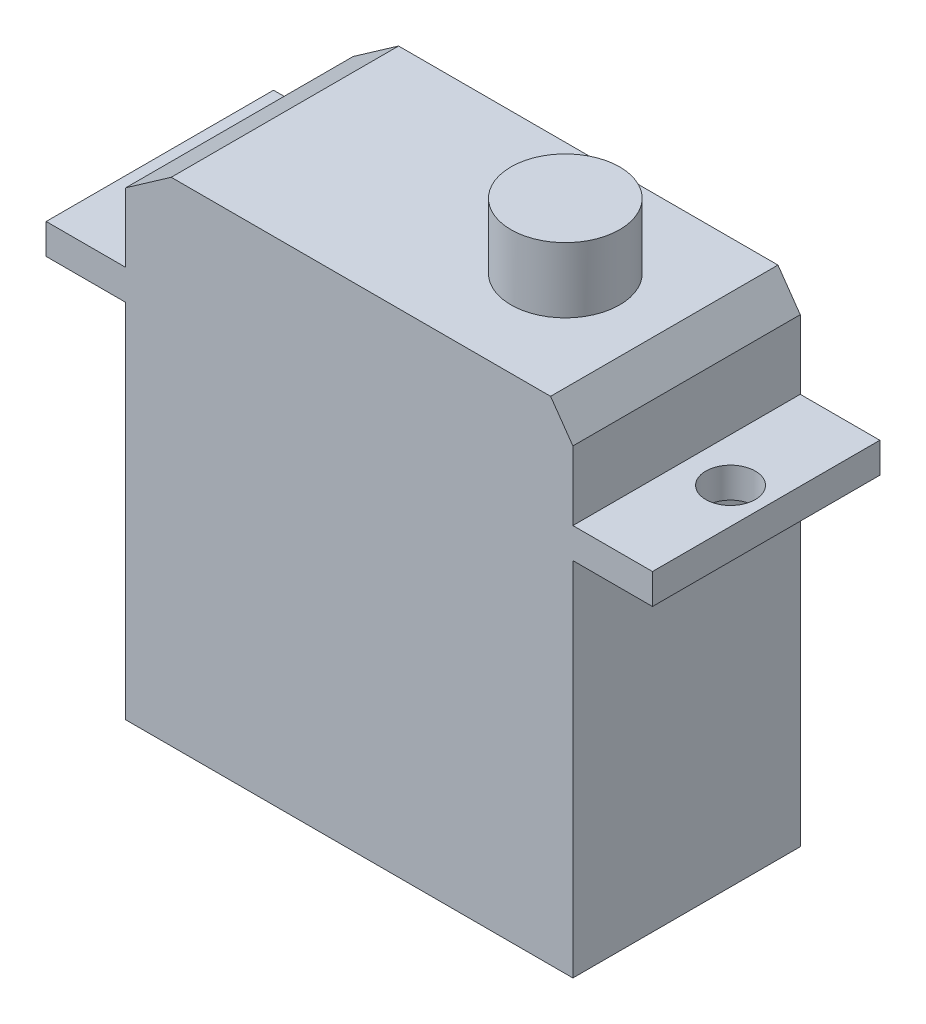
from build123d import *

# Parameters (mm, degrees)
BOSS_EXTRUDE1_DEPTH       = 7.5
SKETCH2_R                 = 3.587141307
BOSS_EXTRUDE2_DEPTH       = 4.3
F_4_CLEARANCE_HOLE1_D     = 3.2639
F_4_CLEARANCE_HOLE1_DEPTH = 5.84
F_4_CLEARANCE_HOLE1_TIP   = 0.980574487


with BuildPart() as part:
    # Sketch1 → Boss-Extrude1 (new body, symmetric)
    with BuildSketch(Plane.XY):
        Polygon((-14.75, 11.925), (-20, 11.925), (-20, 13.925), (-14.75, 13.925), (-14.75, 18.474377385), (-11.75, 20.575), (13.27912821, 20.575), (14.75, 18.474377385), (14.75, 13.925), (20, 13.925), (20, 11.925), (14.75, 11.925), (14.75, -11.925), (-14.75, -11.925), align=None)
    extrude(amount=BOSS_EXTRUDE1_DEPTH, both=True)

    # Sketch2 → Boss-Extrude2 (add)
    with BuildSketch(Plane(origin=(0, 20.575, 0), x_dir=(1, 0, 0), z_dir=(0, 1, 0))):
        with Locations((6.75, 0)):
            Circle(SKETCH2_R)
    extrude(amount=BOSS_EXTRUDE2_DEPTH)

    # 4 Clearance Hole1
    with Locations(Plane(origin=(0, 13.925, 0), x_dir=(1, 0, 0), z_dir=(0, 1, 0))):
        with Locations((-17.65, 0), (17.65, 0)):
            Hole(F_4_CLEARANCE_HOLE1_D / 2, depth=F_4_CLEARANCE_HOLE1_DEPTH)
            with Locations((0, 0, -(F_4_CLEARANCE_HOLE1_DEPTH + F_4_CLEARANCE_HOLE1_TIP / 2))):  # 118° drill point
                Cone(0, F_4_CLEARANCE_HOLE1_D / 2, F_4_CLEARANCE_HOLE1_TIP, mode=Mode.SUBTRACT)


solid = part.part
